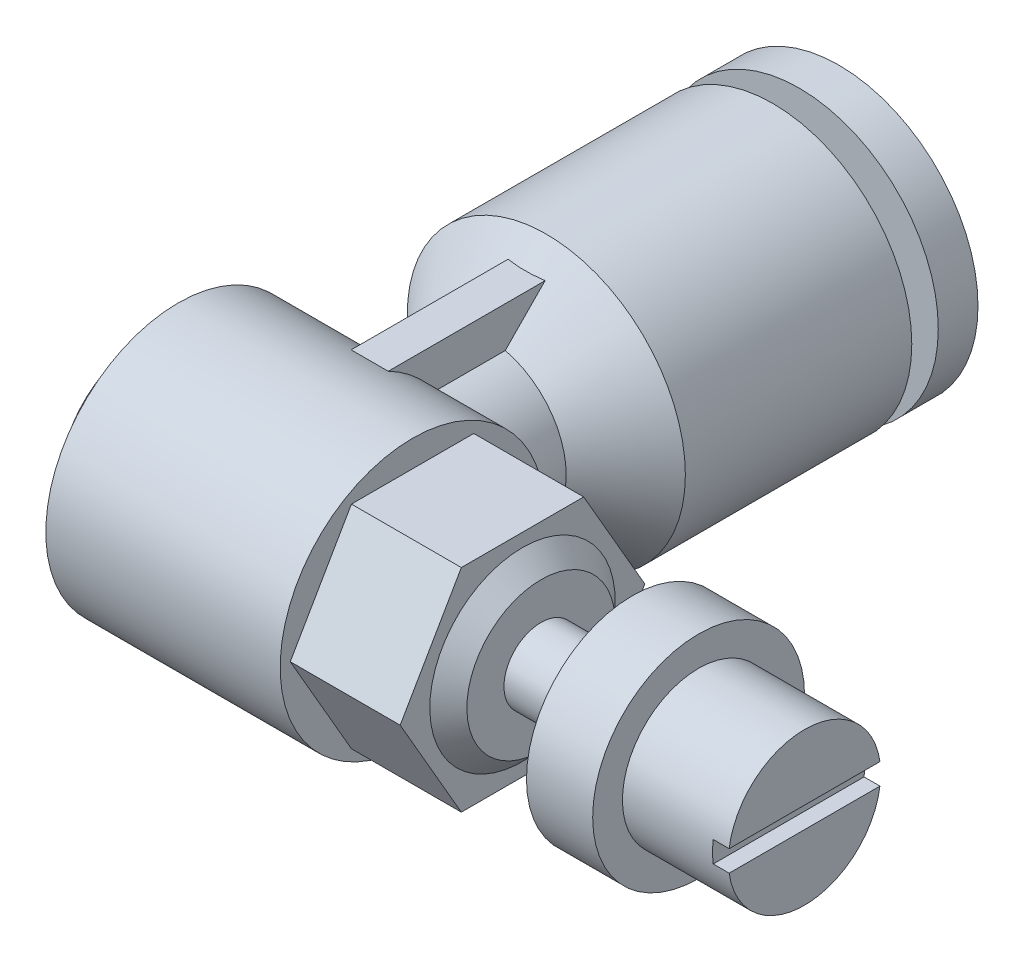
from build123d import *

# Parameters (mm, degrees)
SKETCH2_OUTSIDE_W   = 17.744
SKETCH2_OUTSIDE_H   = 17.744
CUT_EXTRUDE1_DEPTH  = 4.15
SKETCH3_W           = 6.384434702
SKETCH3_H           = 0.8
CUT_EXTRUDE2_DEPTH  = 0.6
SKETCH5_W           = 1.4
SKETCH5_H           = 8.9
BOSS_EXTRUDE1_DEPTH = 10


with BuildPart() as part:
    # Sketch1 → Revolve1 (revolve)
    with BuildSketch(Plane.XY):
        Polygon((0, 0), (0, 3.125), (1.35, 3.125), (1.35, 5), (14.35, 5), (14.35, 3.5), (15.05, 2.8), (15.05, 1.4), (18.5, 1.4), (18.5, 4), (21, 4), (21, 2.875), (25, 2.875), (25, 0), align=None)
    revolve(axis=Axis((25, 0, 0), (-1, 0, 0)))

    # Sketch2 outside → Cut-Extrude1 (cut)
    with BuildSketch(Plane(origin=(14.35, 0, 0), x_dir=(0, 0, -1), z_dir=(1, 0, 0))):
        Rectangle(SKETCH2_OUTSIDE_W, SKETCH2_OUTSIDE_H)
        Polygon((4.618802154, 0), (2.309401077, 4), (-2.309401077, 4), (-4.618802154, 0), (-2.309401077, -4), (2.309401077, -4), align=None, mode=Mode.SUBTRACT)
    extrude(amount=-CUT_EXTRUDE1_DEPTH, mode=Mode.SUBTRACT)

    # Sketch3 → Cut-Extrude2 (cut)
    with BuildSketch(Plane(origin=(25, 0, 0), x_dir=(0, 0, -1), z_dir=(1, 0, 0))):
        Rectangle(SKETCH3_W, SKETCH3_H)
    extrude(amount=-CUT_EXTRUDE2_DEPTH, mode=Mode.SUBTRACT)

    # Sketch4 → Revolve2 (revolve)
    with BuildSketch(Plane(origin=(0, 0, 0), x_dir=(1, 0, 0), z_dir=(0, 1, 0))):
        Polygon((6.3, 0), (6.3, 10.947554121), (4.15, 10.947554121), (4.15, 20), (1.05, 20), (1.05, 18.5), (3.7, 18.5), (3.7, 17.5), (1.05, 17.5), (1.05, 8.95), (3.3, 6.7), (3.3, 0), align=None)
    revolve(axis=Axis((6.3, 0, 0), (0, 0, -1)))

    # Sketch5 → Boss-Extrude1 (add)
    with BuildSketch(Plane.XY):
        with Locations((6.3, 0)):
            Rectangle(SKETCH5_W, SKETCH5_H)
    extrude(amount=-BOSS_EXTRUDE1_DEPTH)


solid = part.part
